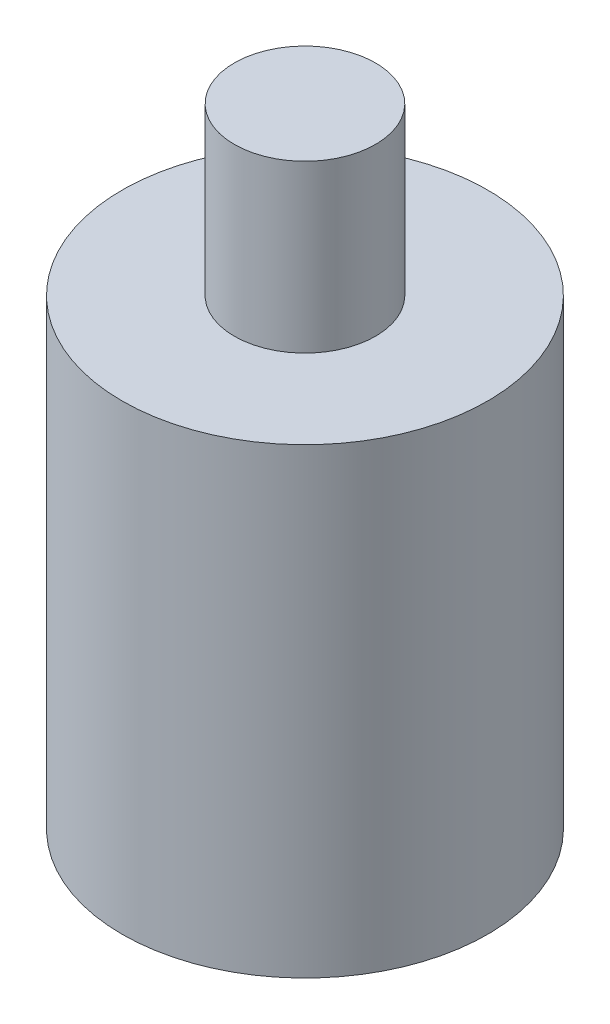
from build123d import *

# Parameters (mm, degrees)
SKETCH1_R           = 110
BOSS_EXTRUDE1_DEPTH = 278
SKETCH2_R           = 42.5
BOSS_EXTRUDE2_DEPTH = 100


with BuildPart() as part:
    # Sketch1 → Boss-Extrude1 (new body)
    with BuildSketch(Plane(origin=(0, 0, 0), x_dir=(1, 0, 0), z_dir=(0, 1, 0))):
        Circle(SKETCH1_R)
    extrude(amount=BOSS_EXTRUDE1_DEPTH)

    # Sketch2 → Boss-Extrude2 (add)
    with BuildSketch(Plane(origin=(0, 278, 0), x_dir=(1, 0, 0), z_dir=(0, 1, 0))):
        Circle(SKETCH2_R)
    extrude(amount=BOSS_EXTRUDE2_DEPTH)


solid = part.part
